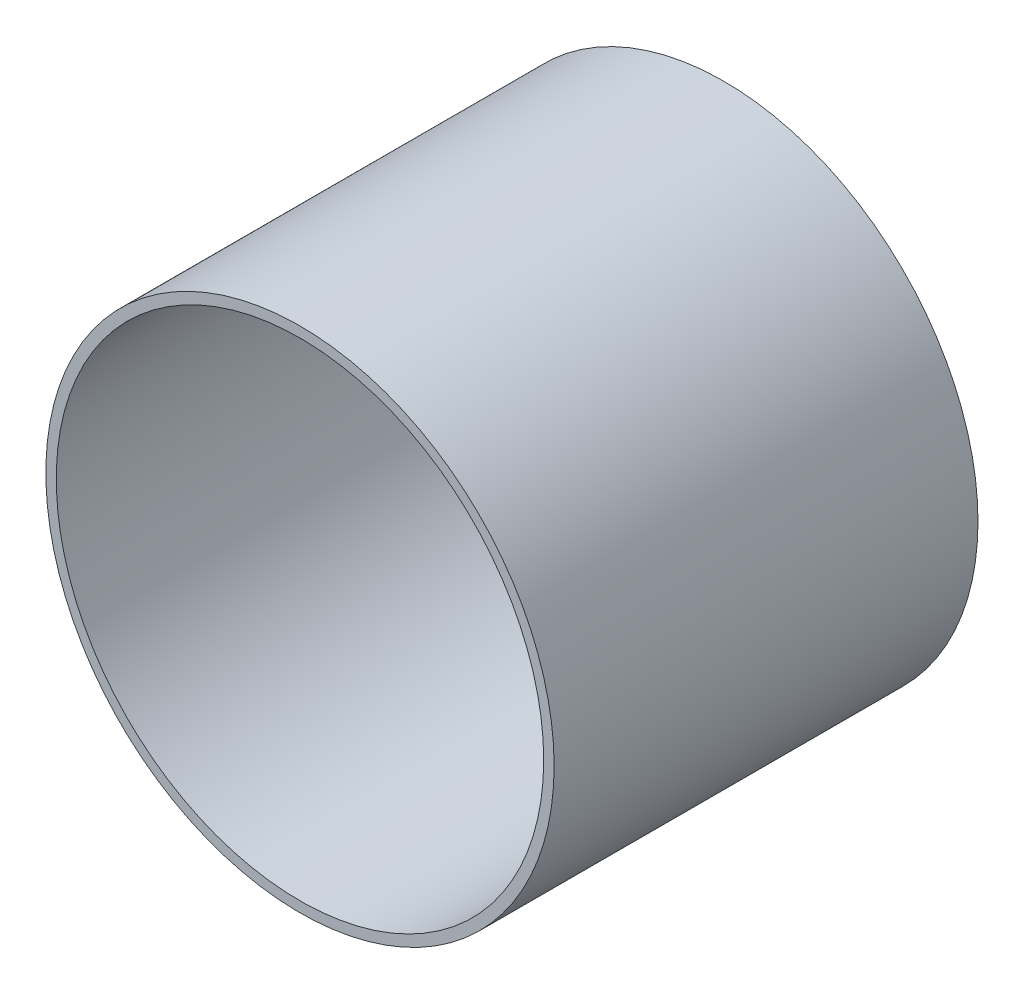
from build123d import *

# Parameters (mm, degrees)
SKETCH1_R           = 38.0746
SKETCH1_R_2         = 36.5125
BOSS_EXTRUDE1_DEPTH = 31.75


with BuildPart() as part:
    # Sketch1 → Boss-Extrude1 (new body, symmetric)
    with BuildSketch(Plane.XY):
        Circle(SKETCH1_R)
        Circle(SKETCH1_R_2, mode=Mode.SUBTRACT)
    extrude(amount=BOSS_EXTRUDE1_DEPTH, both=True)


solid = part.part
